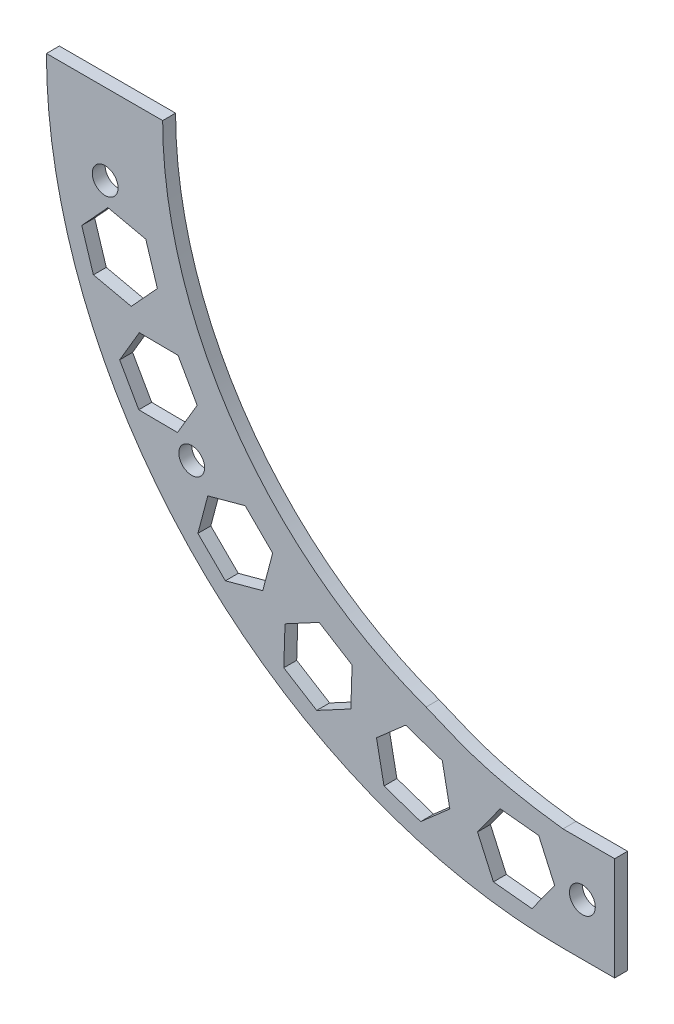
from build123d import *

# Parameters (mm, degrees)
BOSS_EXTRUDE1_DEPTH = 6.35
CUT_EXTRUDE1_REACH  = 8.35
SKETCH3_R           = 6.35
CUT_EXTRUDE2_REACH  = 8.35
SKETCH4_R           = 6.35
BOSS_EXTRUDE2_DEPTH = 6.35
CUT_EXTRUDE4_DEPTH  = 7.3500001


with BuildPart() as part:
    # Sketch1 → Boss-Extrude1 (new body)
    with BuildSketch(Plane.XY):
        with BuildLine():
            Line((0, -203.2), (25.4, -203.2))
            Line((25.4, -203.2), (25.4, -254))
            Line((25.4, -254), (0, -254))
            ThreePointArc((0, -254), (-179.605122421, -179.605122421), (-254, 0))
            Line((-254, 0), (-203.2, 0))
            ThreePointArc((-203.2, 0), (-143.684097937, -143.684097937), (0, -203.2))
        make_face()
    extrude(amount=BOSS_EXTRUDE1_DEPTH)

    # Sketch3 → Cut-Extrude1 (cut, up to next)
    with BuildSketch(Plane.XY.offset(6.35), mode=Mode.PRIVATE) as cut_extrude1_sk1:
        with Locations((-182.568077597, -137.574914293)):
            Circle(SKETCH3_R)
    cut_extrude1_tool1 = extrude(cut_extrude1_sk1.sketch, amount=-CUT_EXTRUDE1_REACH, mode=Mode.PRIVATE) & part.part
    add(cut_extrude1_tool1.solids().sort_by_distance((-182.568078, -137.574914, 6.35))[0], mode=Mode.SUBTRACT)
    # Sketch3 → Cut-Extrude1 (cut, up to next)
    with BuildSketch(Plane.XY.offset(6.35), mode=Mode.PRIVATE) as cut_extrude1_sk2:
        with Locations((-225.127052339, -39.695973415)):
            Circle(SKETCH3_R)
    cut_extrude1_tool2 = extrude(cut_extrude1_sk2.sketch, amount=-CUT_EXTRUDE1_REACH, mode=Mode.PRIVATE) & part.part
    add(cut_extrude1_tool2.solids().sort_by_distance((-225.127052, -39.695973, 6.35))[0], mode=Mode.SUBTRACT)

    # Sketch4 → Cut-Extrude2 (cut, up to next)
    with BuildSketch(Plane.XY.offset(6.35), mode=Mode.PRIVATE) as cut_extrude2_sk1:
        with Locations((9.525, -228.6)):
            Circle(SKETCH4_R)
    cut_extrude2_tool1 = extrude(cut_extrude2_sk1.sketch, amount=-CUT_EXTRUDE2_REACH, mode=Mode.PRIVATE) & part.part
    add(cut_extrude2_tool1.solids().sort_by_distance((9.525, -228.6, 6.35))[0], mode=Mode.SUBTRACT)

    # Sketch5 → Boss-Extrude2 (add)
    with BuildSketch(Plane.XY.offset(6.35)):
        with BuildLine():
            Line((-196.85, 0), (-203.2, 0))
            ThreePointArc((-203.2, 0), (-143.684097937, -143.684097937), (0, -203.2))
            add(Edge.make_bspline(
                [(0, -203.2), (-42.738576364, -198.027670234), (-55.377716847, -189.330212239), (-67.326665214, -184.978492402)],
                knots=[0, 0, 0, 0, 1, 1, 1, 1], degree=3))
            ThreePointArc((-67.326665214, -184.978492402), (-161.250079918, -112.908521496), (-196.85, 0))
        make_face()
    extrude(amount=-BOSS_EXTRUDE2_DEPTH)

    # Sketch8 → Cut-Extrude4 (cut, through all)
    with BuildSketch(Plane.XY.offset(6.35)):
        Polygon((-189.550744798, -129.195114639), (-179.886192663, -112.778692007), (-189.270955635, -96.200733026), (-208.320270741, -96.039196678), (-217.984822875, -112.45561931), (-208.600059904, -129.033578291), align=None)
        Polygon((-212.312705004, -86.857226492), (-199.439243548, -72.815271852), (-205.163202257, -54.645549875), (-223.760622423, -50.51778254), (-236.634083879, -64.559737181), (-230.91012517, -82.729459157), align=None)
        Polygon((-147.628804374, -175.575051243), (-142.755562385, -157.158916673), (-156.267781768, -143.730498026), (-174.65324314, -148.71821395), (-179.526485129, -167.134348521), (-166.014265746, -180.562767167), align=None)
        Polygon((-104.315468483, -204.301604338), (-103.713008923, -185.261133166), (-119.901310879, -175.219152296), (-136.692072394, -184.217642598), (-137.294531954, -203.258113771), (-121.106229998, -213.300094641), align=None)
        Polygon((-55.647161568, -222.540459039), (-59.346411332, -203.853082252), (-77.379779242, -197.713038129), (-91.713897388, -210.260370793), (-88.014647624, -228.94774758), (-69.981279714, -235.087791703), align=None)
        Polygon((-4.122241516, -229.355334852), (-11.933301871, -211.980357553), (-30.886003779, -210.057445601), (-42.027645333, -225.509510947), (-34.216584978, -242.884488246), (-15.26388307, -244.807400198), align=None)
    extrude(amount=-CUT_EXTRUDE4_DEPTH, mode=Mode.SUBTRACT)


solid = part.part
